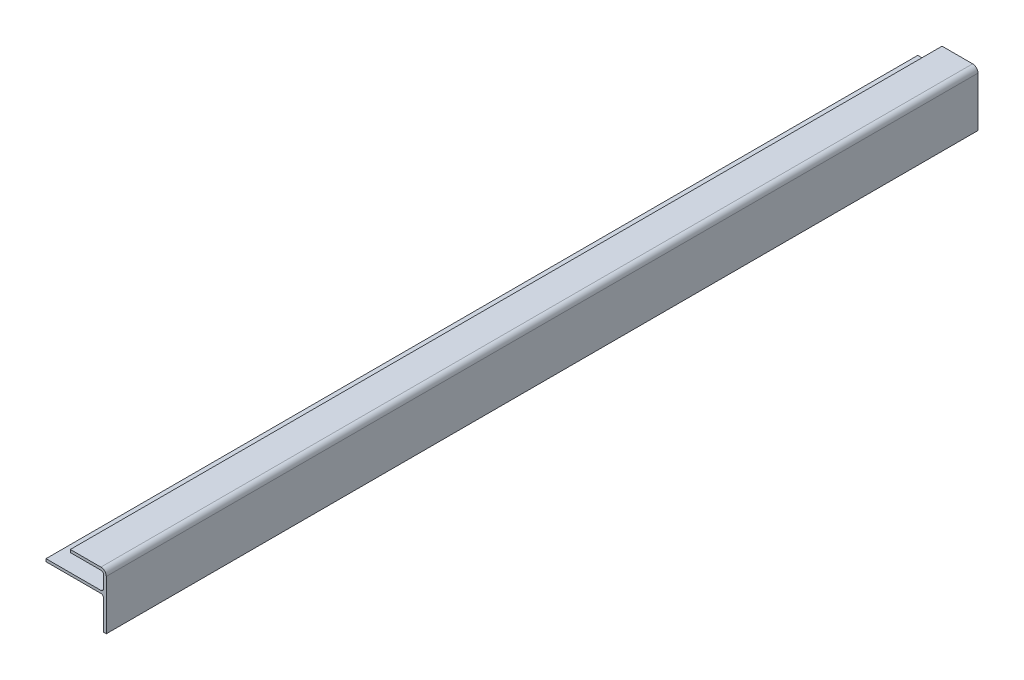
from build123d import *

# Parameters (mm, degrees)
EXTRUDE1_DEPTH = 257.175


with BuildPart() as part:
    # Sketch1 → Extrude1 (new body, symmetric)
    with BuildSketch(Plane.XY):
        with BuildLine():
            Line((1219.2, 19.05), (1219.2, 36.5125))
            ThreePointArc((1219.2, 36.5125), (1218.735032015, 37.635032015), (1217.6125, 38.1))
            Line((1217.6125, 38.1), (1185.2275, 38.1))
            Line((1185.2275, 38.1), (1185.2275, 39.6875))
            Line((1185.2275, 39.6875), (1217.6125, 39.6875))
            ThreePointArc((1217.6125, 39.6875), (1218.735032015, 40.152467985), (1219.2, 41.275))
            Line((1219.2, 41.275), (1219.2, 48.387))
            ThreePointArc((1219.2, 48.387), (1218.735032015, 49.509532015), (1217.6125, 49.9745))
            Line((1217.6125, 49.9745), (1199.5785, 49.9745))
            Line((1199.5785, 49.9745), (1199.5785, 51.562))
            Line((1199.5785, 51.562), (1217.6125, 51.562))
            ThreePointArc((1217.6125, 51.562), (1219.85756403, 50.63206403), (1220.7875, 48.387))
            Line((1220.7875, 48.387), (1220.7875, 19.05))
            Line((1220.7875, 19.05), (1219.2, 19.05))
        make_face()
    extrude(amount=EXTRUDE1_DEPTH, both=True)


solid = part.part
